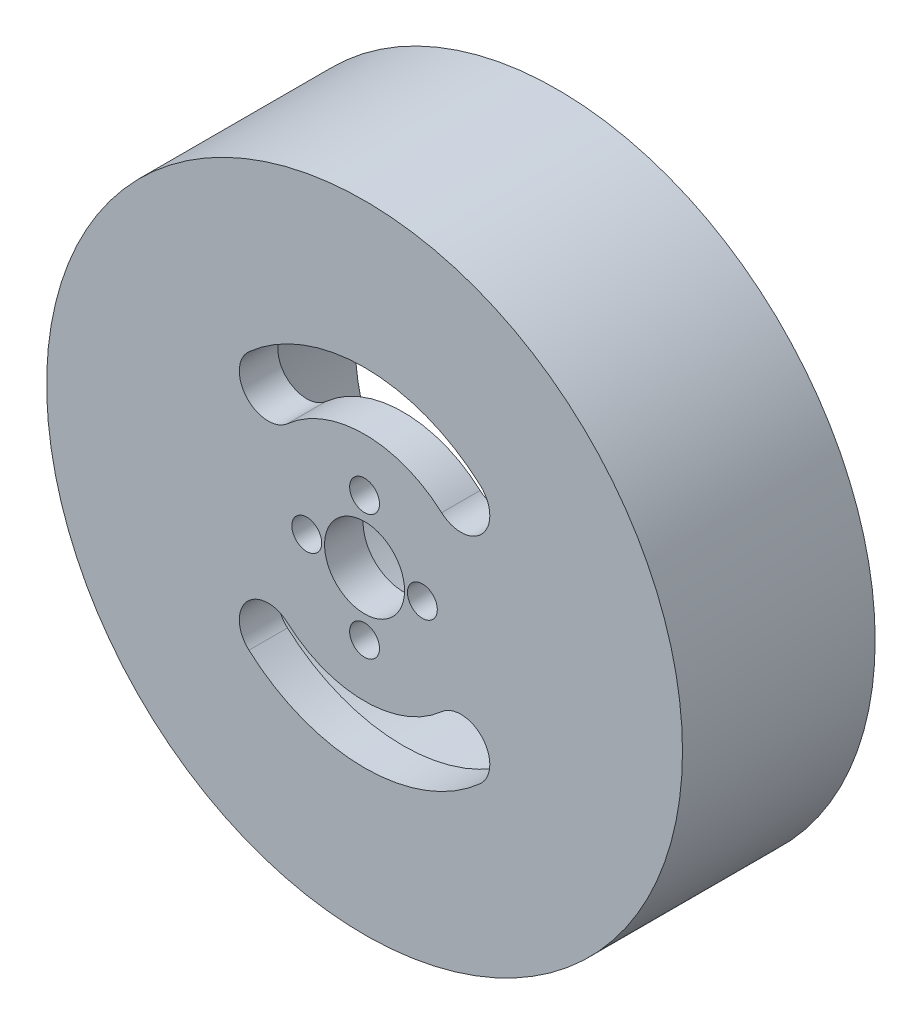
from build123d import *

# Parameters (mm, degrees)
SKETCH_1_R          = 33
EXTRUDE_1_DEPTH     = 20
CUT_EXTRUDE_2_DEPTH = 25
SKETCH_1_6_R        = 21
CUT_EXTRUDE_3_DEPTH = 16
CUT_EXTRUDE_5_DEPTH = 30


with BuildPart() as part:
    # 草图1 → 凸台-拉伸1 (new body)
    with BuildSketch(Plane.XY):
        Circle(SKETCH_1_R)
    extrude(amount=EXTRUDE_1_DEPTH)

    # 草图1<5> → 切除-拉伸2 (cut, symmetric)
    with BuildSketch(Plane.XY):
        with BuildLine():
            ThreePointArc((-8, -8.94427191), (-8.929533731, -8.377822811), (-10, -8.180339887))
            ThreePointArc((-10, -8.180339887), (-12.802517077, -10.109873618), (-12, -13.416407865))
            ThreePointArc((-12, -13.416407865), (0, -18), (12, -13.416407865))
            ThreePointArc((12, -13.416407865), (12.802517077, -10.109873618), (10, -8.180339887))
            ThreePointArc((10, -8.180339887), (8.929533731, -8.377822811), (8, -8.94427191))
            ThreePointArc((8, -8.94427191), (0, -12), (-8, -8.94427191))
        make_face()
        with BuildLine():
            ThreePointArc((-12, 13.416407865), (-12.236067977, 9.180339887), (-8, 8.94427191))
            ThreePointArc((-8, 8.94427191), (-4.281865077, 11.210068308), (0, 12))
            ThreePointArc((0, 12), (4.281865077, 11.210068308), (8, 8.94427191))
            ThreePointArc((8, 8.94427191), (12.236067977, 9.180339887), (12, 13.416407865))
            ThreePointArc((12, 13.416407865), (6.422797616, 16.815102461), (0, 18))
            ThreePointArc((0, 18), (-6.422797616, 16.815102461), (-12, 13.416407865))
        make_face()
    extrude(amount=CUT_EXTRUDE_2_DEPTH, both=True, mode=Mode.SUBTRACT)

    # 草图1<6> → 切除-拉伸3 (cut)
    with BuildSketch(Plane.XY):
        Circle(SKETCH_1_6_R)
    extrude(amount=CUT_EXTRUDE_3_DEPTH, mode=Mode.SUBTRACT)

    # 草图1<7> → 切除-拉伸5 (cut, symmetric)
    with BuildSketch(Plane.XY):
        with BuildLine():
            ThreePointArc((0, 8.05), (-1.55, 6.5), (0, 4.95))
            ThreePointArc((0, 4.95), (1.55, 6.5), (0, 8.05))
        make_face()
        with BuildLine():
            ThreePointArc((0, -4.95), (-1.55, -6.5), (0, -8.05))
            ThreePointArc((0, -8.05), (1.55, -6.5), (0, -4.95))
        make_face()
        with BuildLine():
            ThreePointArc((6, 1.55), (4.45, 0), (6, -1.55))
            ThreePointArc((6, -1.55), (7.55, 0), (6, 1.55))
        make_face()
        with BuildLine():
            ThreePointArc((-6, 1.55), (-7.55, 0), (-6, -1.55))
            ThreePointArc((-6, -1.55), (-4.45, 0), (-6, 1.55))
        make_face()
        with BuildLine():
            ThreePointArc((0, 4.15), (-4.15, 0), (0, -4.15))
            ThreePointArc((0, -4.15), (4.15, 0), (0, 4.15))
        make_face()
    extrude(amount=CUT_EXTRUDE_5_DEPTH, both=True, mode=Mode.SUBTRACT)


solid = part.part
